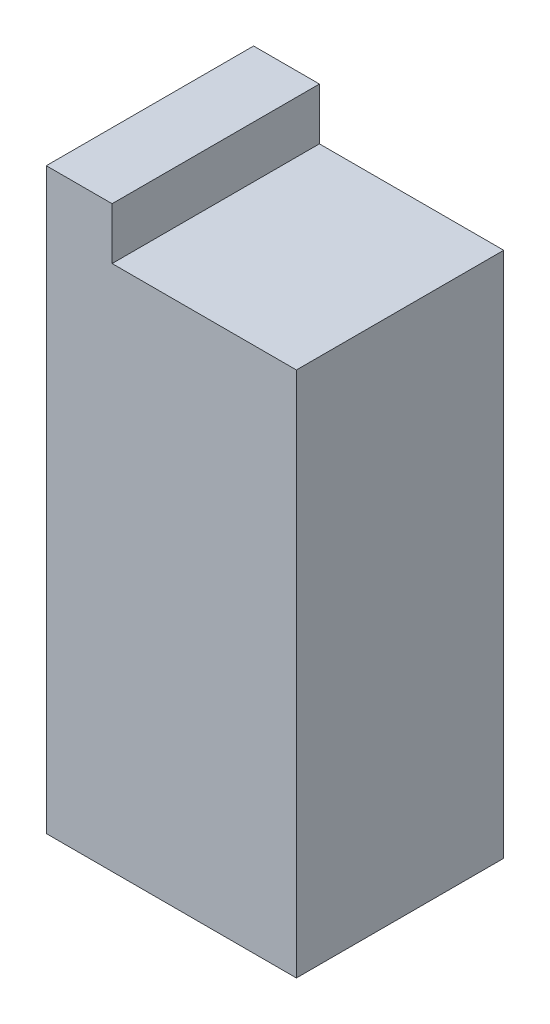
from build123d import *

# Parameters (mm, degrees)
BOSS_EXTRUDE1_DEPTH = 10


with BuildPart() as part:
    # Sketch1 → Boss-Extrude1 (new body, symmetric)
    with BuildSketch(Plane.XY):
        Polygon((-8.89, -25.4), (8.89, -25.4), (8.89, 25.4), (-8.89, 25.4), (-8.89, 30.4), (-15.24, 30.4), (-15.24, -25.4), align=None)
    extrude(amount=BOSS_EXTRUDE1_DEPTH, both=True)


solid = part.part
